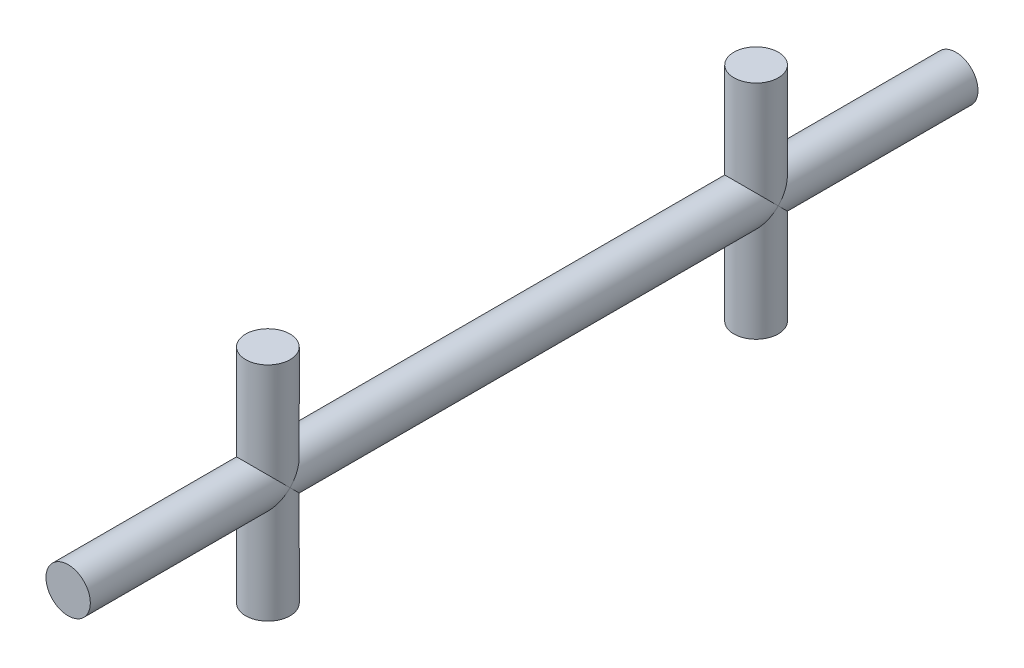
from build123d import *

# Parameters (mm, degrees)
ESQUISSE1_R             = 1
BOSS_EXTRU_1_DEPTH      = 40
ESQUISSE2_R             = 1
BOSS_EXTRU_2_DEPTH      = 5
BOSS_EXTRU_2_DEPTH_BACK = 5


with BuildPart() as part:
    # Esquisse1 → Boss.-Extru.1 (new body)
    with BuildSketch(Plane.XY):
        Circle(ESQUISSE1_R)
    extrude(amount=-BOSS_EXTRU_1_DEPTH)

    # Esquisse2 → Boss.-Extru.2 (add, two sides)
    with BuildSketch(Plane(origin=(0, 0, 0), x_dir=(1, 0, 0), z_dir=(0, 1, 0))) as boss_extru_2_sk:
        with Locations(Location((0, 9, 0), (0, 0, 270))):  # turned: the seam where the file's is
            Circle(ESQUISSE2_R)
        with Locations(Location((0, 31, 0), (0, 0, 270))):  # turned: the seam where the file's is
            Circle(ESQUISSE2_R)
    extrude(amount=BOSS_EXTRU_2_DEPTH)
    extrude(boss_extru_2_sk.sketch, amount=-BOSS_EXTRU_2_DEPTH_BACK)


solid = part.part
